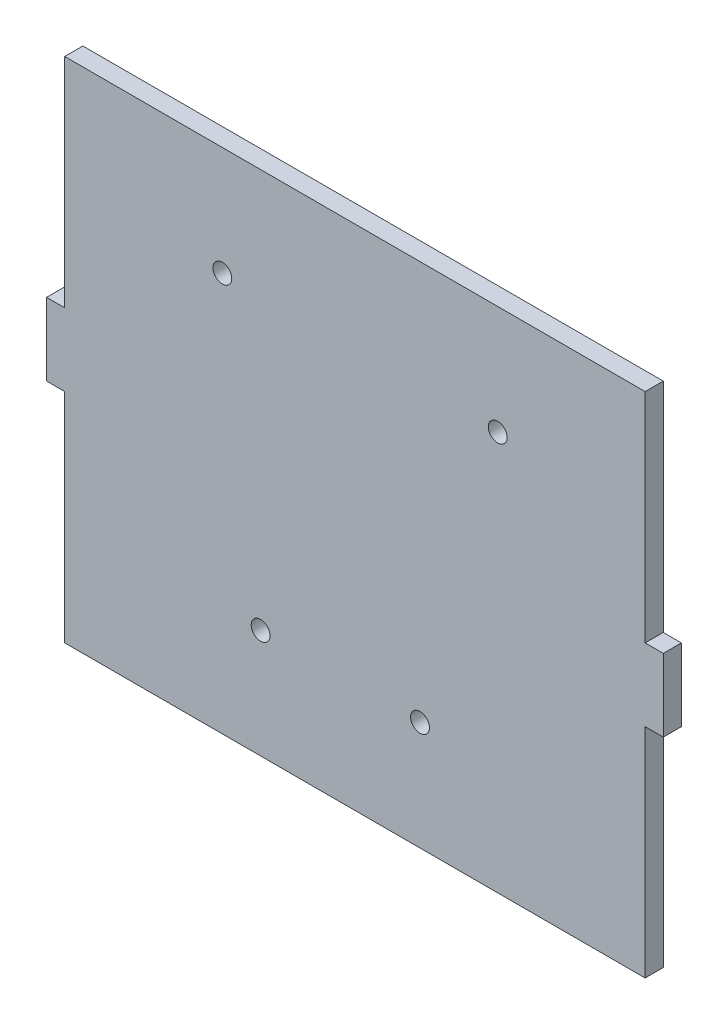
from build123d import *

# Parameters (mm, degrees)
SKETCH1_W           = 101.6
SKETCH1_H           = 88.9
BOSS_EXTRUDE1_DEPTH = 3.175
SKETCH2_W           = 3.175
SKETCH2_H           = 12.7
BOSS_EXTRUDE2_DEPTH = 3.175
SKETCH3_R           = 1.65
CUT_EXTRUDE1_DEPTH  = 4.175


with BuildPart() as part:
    # Sketch1 → Boss-Extrude1 (new body)
    with BuildSketch(Plane.XY):
        with Locations((50.8, 44.45)):
            Rectangle(SKETCH1_W, SKETCH1_H)
    extrude(amount=BOSS_EXTRUDE1_DEPTH)

    # Sketch2 → Boss-Extrude2 (add)
    with BuildSketch(Plane.XY.offset(3.175)):
        with Locations((-1.5875, 44.45)):
            Rectangle(SKETCH2_W, SKETCH2_H)
        with Locations((103.1875, 44.45)):
            Rectangle(SKETCH2_W, SKETCH2_H)
    extrude(amount=-BOSS_EXTRUDE2_DEPTH)

    # Sketch3 → Cut-Extrude1 (cut, through all)
    with BuildSketch(Plane.XY.offset(3.175)):
        with Locations((27.589999938, 69.85)):
            Circle(SKETCH3_R)
        with Locations((75.790000058, 69.85)):
            Circle(SKETCH3_R)
        with Locations((62.19000008, 19.05)):
            Circle(SKETCH3_R)
        with Locations((34.29, 19.05)):
            Circle(SKETCH3_R)
    extrude(amount=-CUT_EXTRUDE1_DEPTH, mode=Mode.SUBTRACT)


solid = part.part
